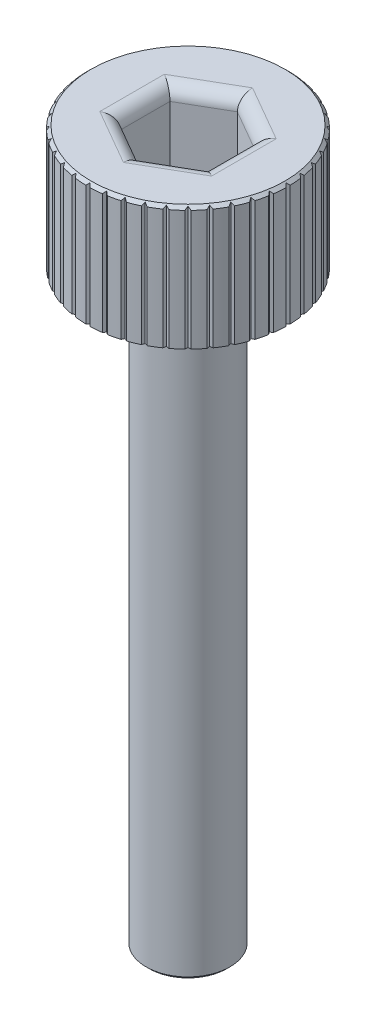
from build123d import *

# Parameters (mm, degrees)
CUT_EXTRUDE1_DEPTH = 4.064
FILLET1_R          = 0.762
CUT_EXTRUDE3_DEPTH = 9.144
CIRPATTERN1_COUNT  = 40


with BuildPart() as part:
    # Sketch1 → Revolve1 (revolve)
    with BuildSketch(Plane.XY):
        Polygon((0, 0), (0, 41.1734), (5.611594878, 41.1734), (5.7912, 40.993794878), (5.7912, 34.036), (2.4257, 34.036), (2.4257, 0.179605122), (2.246094878, 0), align=None)
    revolve(axis=Axis((0, 0, 0), (0, 1, 0)))

    # Sketch2 → Cut-Extrude1 (cut)
    with BuildSketch(Plane(origin=(0, 41.1734, 0), x_dir=(1, 0, 0), z_dir=(0, 1, 0))):
        Polygon((0, -2.8575), (2.474667591, -1.42875), (2.474667591, 1.42875), (0, 2.8575), (-2.474667591, 1.42875), (-2.474667591, -1.42875), align=None)
    extrude(amount=-CUT_EXTRUDE1_DEPTH, mode=Mode.SUBTRACT)

    # Fillet1
    fillet1_edges = [part.edges().sort_by_distance(p)[0] for p in [
        (-1.237333796, 41.1734, 2.143125),
        (1.237333796, 41.1734, 2.143125),
        (2.474667591, 41.1734, 0),
        (1.237333796, 41.1734, -2.143125),
        (-1.237333796, 41.1734, -2.143125),
        (-2.474667591, 41.1734, 0),
    ]]
    fillet(fillet1_edges, radius=FILLET1_R)

    # Sketch3 → Cut-Extrude3 (cut)
    with BuildSketch(Plane(origin=(0, 41.1734, 0), x_dir=(1, 0, 0), z_dir=(0, 1, 0))):
        Polygon((0, 5.6642), (-2.032, 7.6962), (2.032, 7.6962), align=None)
    cut_extrude3 = extrude(amount=-CUT_EXTRUDE3_DEPTH, mode=Mode.SUBTRACT)

    # CirPattern1: Cut-Extrude3 ×40 about axis
    cirpattern1_axis = Axis((0, 0, 0), (0, 1, 0))
    for i in range(1, CIRPATTERN1_COUNT):
        add(cut_extrude3.rotate(cirpattern1_axis, i * 360 / CIRPATTERN1_COUNT), mode=Mode.SUBTRACT)


solid = part.part
